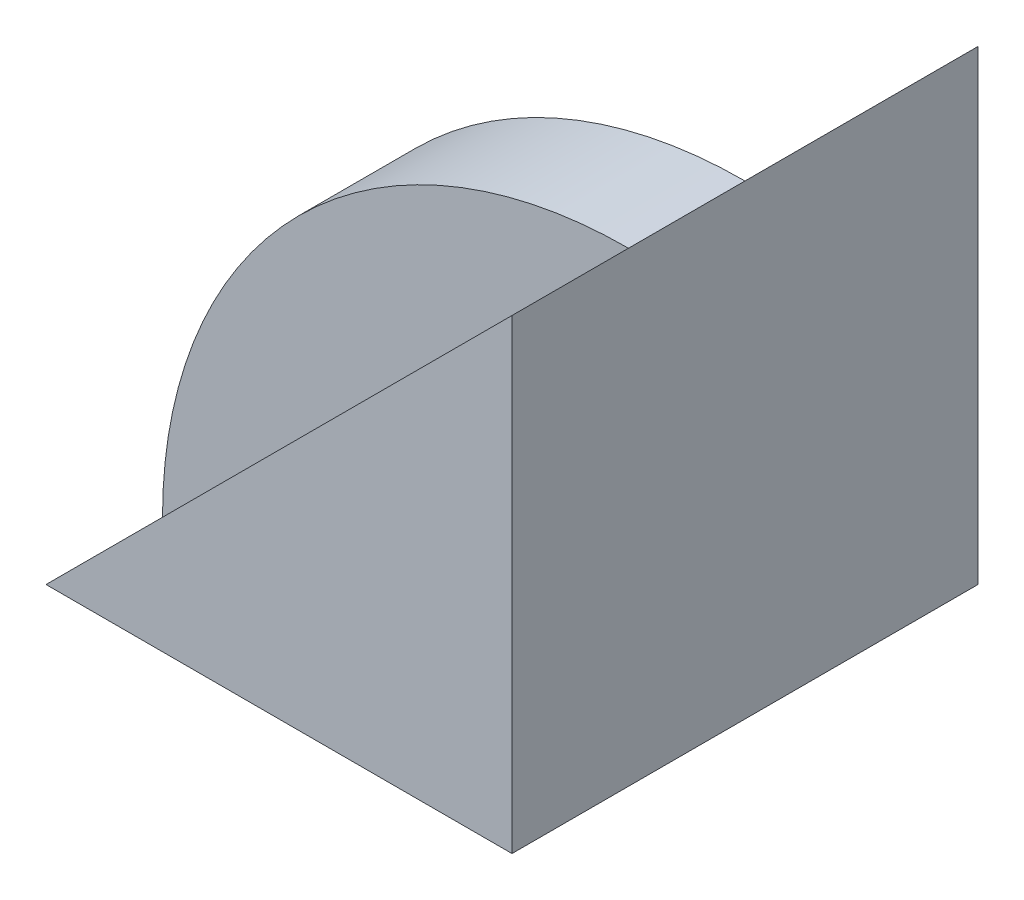
from build123d import *

# Parameters (mm, degrees)
BOSS_EXTRUDE1_DEPTH = 10
BOSS_EXTRUDE2_DEPTH = 10
BOSS_EXTRUDE4_DEPTH = 20
CUT_EXTRUDE3_DEPTH  = 57


with BuildPart() as part:
    # Sketch1 → Boss-Extrude1 (new body)
    with BuildSketch(Plane.XY):
        Polygon((0, 0), (-40, 0), (0, 40), align=None)
    extrude(amount=BOSS_EXTRUDE1_DEPTH)

    # Sketch2 → Boss-Extrude2 (add)
    with BuildSketch(Plane(origin=(0, 0, 0), x_dir=(-1, 0, 0), z_dir=(0, 0, -1))):
        with BuildLine():
            Line((0, 40), (0, 0))
            Line((0, 0), (40, 0))
            ThreePointArc((40, 0), (28.284271247, 28.284271247), (0, 40))
        make_face()
    extrude(amount=BOSS_EXTRUDE2_DEPTH)

    # Sketch3 → Boss-Extrude4 (add)
    with BuildSketch(Plane(origin=(0, 0, -10), x_dir=(-1, 0, 0), z_dir=(0, 0, -1))):
        Polygon((0, 40), (0, 0), (40, 0), align=None)
    extrude(amount=BOSS_EXTRUDE4_DEPTH)

    # Sketch5 → Cut-Extrude3 (cut)
    with BuildSketch(Plane.XZ):
        Polygon((0, -30), (-40, -10), (-40, -30), align=None)
    extrude(amount=-CUT_EXTRUDE3_DEPTH, mode=Mode.SUBTRACT)


solid = part.part
